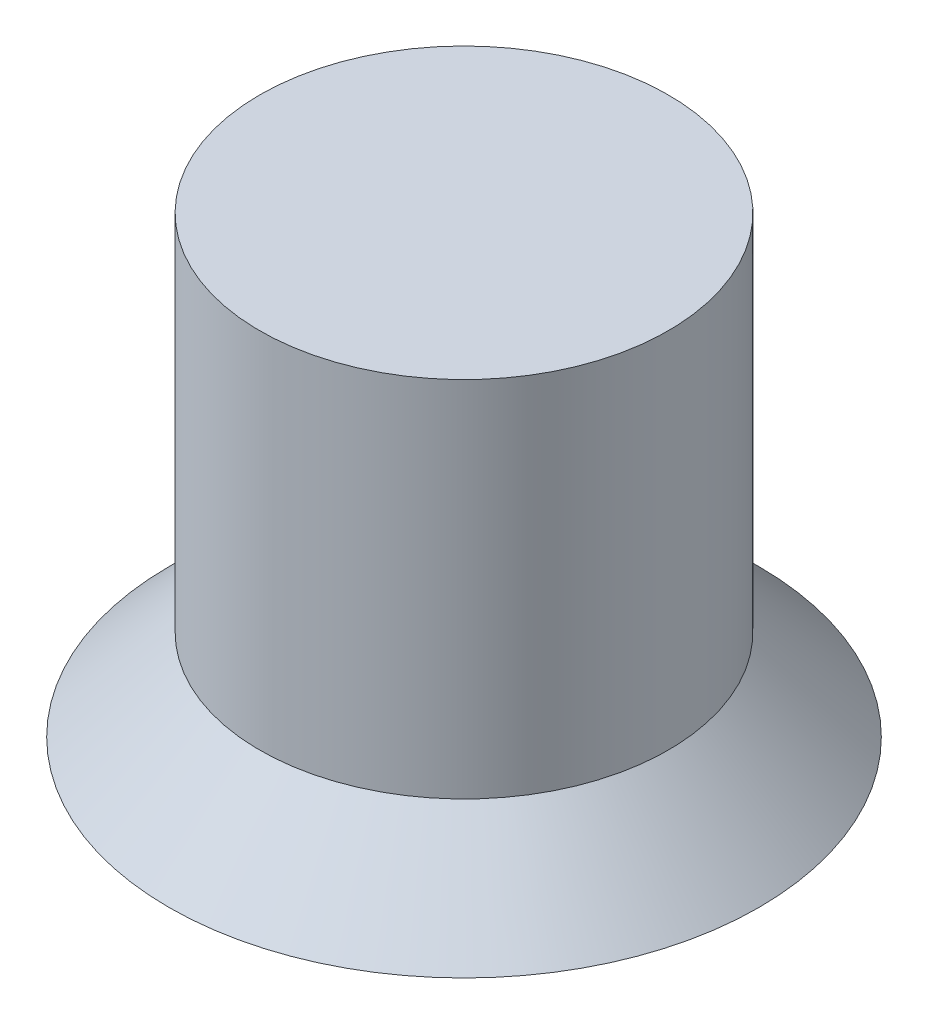
from build123d import *

# Parameters (mm, degrees)
SKETCH2_R           = 1.5
BOSS_EXTRUDE1_DEPTH = 0.5
FILLET1_R           = 0.3


with BuildPart() as part:
    # Sketch1 → Revolve1 (revolve)
    with BuildSketch(Plane.XY, mode=Mode.PRIVATE) as revolve1_sk:
        Polygon((0, 0), (6.5, 0), (4.5, 2), (4.5, 10), (0, 10), align=None)
    revolve(revolve1_sk.sketch.rotate(Axis((0, 10, 0), (0, -1, 0)), 180), axis=Axis((0, 10, 0), (0, -1, 0)))  # turned: the seam where the file's is

    # Sketch2 → Boss-Extrude1 (add)
    with BuildSketch(Plane.XZ):
        with Locations(Location((4, 0, 0), (0, 0, 180))):  # turned: the seam where the file's is
            Circle(SKETCH2_R)
    extrude(amount=BOSS_EXTRUDE1_DEPTH)

    # Fillet1
    fillet1_edges = [part.edges().sort_by_distance(p)[0] for p in [
        (5.5, -0.5, 0),
    ]]
    fillet(fillet1_edges, radius=FILLET1_R)


solid = part.part
